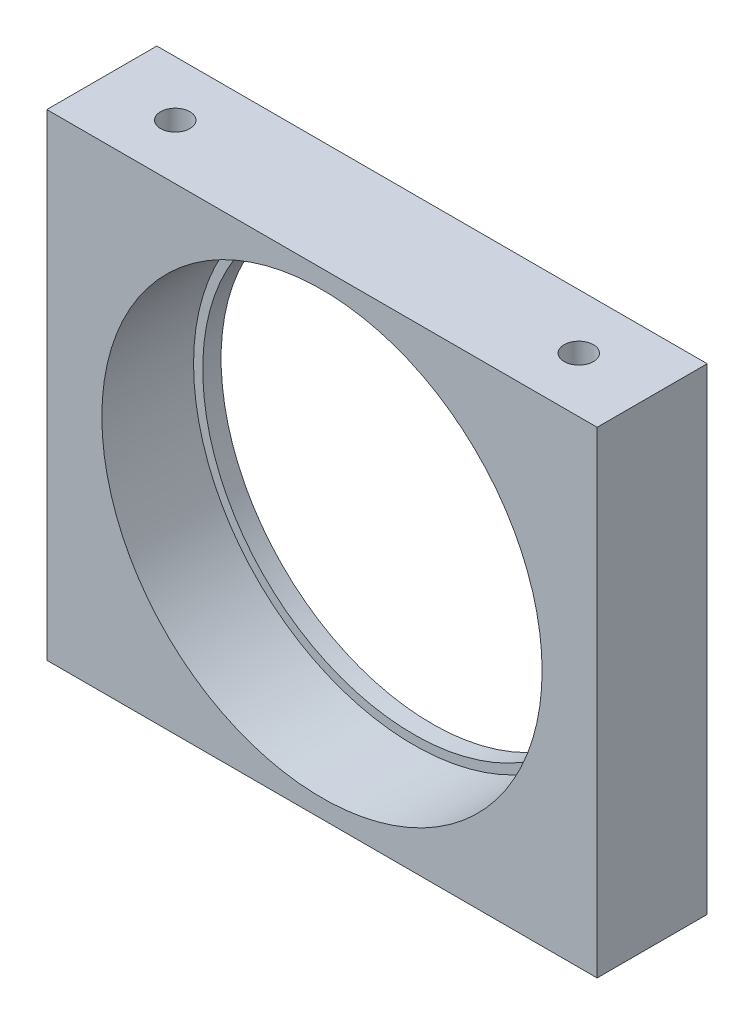
from build123d import *

# Parameters (mm, degrees)
ESQUISSE1_W                                   = 30
ESQUISSE1_H                                   = 26
ESQUISSE1_R                                   = 11.5
BOSS_EXTRU_1_DEPTH                            = 6
ESQUISSE2_R                                   = 12
ENL_V_MAT_EXTRU_1_DEPTH                       = 5
TROU_POUR_TARAUDAGE_POUR_TROU_TARAUD_M2_D     = 1.6
TROU_POUR_TARAUDAGE_POUR_TROU_TARAUD_M2_DEPTH = 5
TROU_POUR_TARAUDAGE_POUR_TROU_TARAUD_M2_TIP   = 0.480688495
TROU_POUR_TARAUDAGE_POUR_TROU_TARAUD_2_D      = 1.6
TROU_POUR_TARAUDAGE_POUR_TROU_TARAUD_2_DEPTH  = 5
TROU_POUR_TARAUDAGE_POUR_TROU_TARAUD_2_TIP    = 0.480688495


with BuildPart() as part:
    # Esquisse1 → Boss.-Extru.1 (new body)
    with BuildSketch(Plane.XY):
        with Locations((15, 13)):
            Rectangle(ESQUISSE1_W, ESQUISSE1_H)
        with Locations((15, 13)):
            Circle(ESQUISSE1_R, mode=Mode.SUBTRACT)
    extrude(amount=BOSS_EXTRU_1_DEPTH)

    # Esquisse2 → Enlèv. mat.-Extru.1 (cut)
    with BuildSketch(Plane.XY.offset(6)):
        with Locations((15, 13)):
            Circle(ESQUISSE2_R)
    extrude(amount=-ENL_V_MAT_EXTRU_1_DEPTH, mode=Mode.SUBTRACT)

    # Trou pour taraudage pour trou taraud_ M2
    with Locations(Plane(origin=(0, 26, 0), x_dir=(1, 0, 0), z_dir=(0, 1, 0))):
        with Locations((4, -3), (26, -3)):
            Hole(TROU_POUR_TARAUDAGE_POUR_TROU_TARAUD_M2_D / 2, depth=TROU_POUR_TARAUDAGE_POUR_TROU_TARAUD_M2_DEPTH)
            with Locations((0, 0, -(TROU_POUR_TARAUDAGE_POUR_TROU_TARAUD_M2_DEPTH + TROU_POUR_TARAUDAGE_POUR_TROU_TARAUD_M2_TIP / 2))):  # 118° drill point
                Cone(0, TROU_POUR_TARAUDAGE_POUR_TROU_TARAUD_M2_D / 2, TROU_POUR_TARAUDAGE_POUR_TROU_TARAUD_M2_TIP, mode=Mode.SUBTRACT)

    # Trou pour taraudage pour trou taraud 2
    with Locations(Plane(origin=(0, 0, 0), x_dir=(-1, 0, 0), z_dir=(0, -1, 0))):
        with Locations((-4, -3), (-26, -3)):
            Hole(TROU_POUR_TARAUDAGE_POUR_TROU_TARAUD_2_D / 2, depth=TROU_POUR_TARAUDAGE_POUR_TROU_TARAUD_2_DEPTH)
            with Locations((0, 0, -(TROU_POUR_TARAUDAGE_POUR_TROU_TARAUD_2_DEPTH + TROU_POUR_TARAUDAGE_POUR_TROU_TARAUD_2_TIP / 2))):  # 118° drill point
                Cone(0, TROU_POUR_TARAUDAGE_POUR_TROU_TARAUD_2_D / 2, TROU_POUR_TARAUDAGE_POUR_TROU_TARAUD_2_TIP, mode=Mode.SUBTRACT)


solid = part.part
